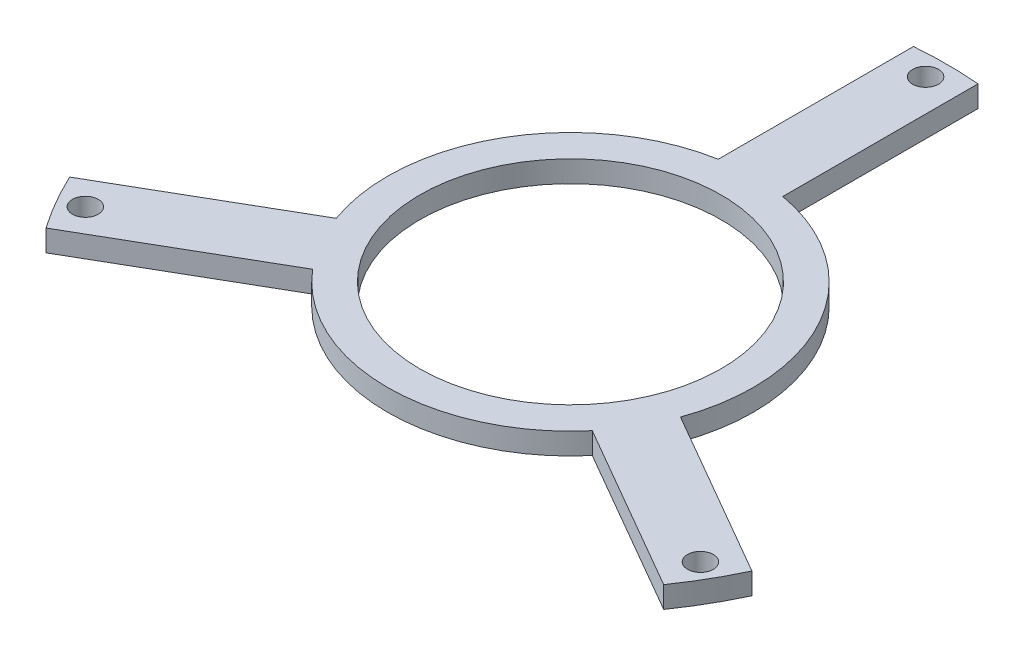
from build123d import *

# Parameters (mm, degrees)
SKETCH_1_R      = 70
SKETCH_1_R_2    = 6
EXTRUDE_1_DEPTH = 10


with BuildPart() as part:
    # 草图1 → 凸台-拉伸1 (new body)
    with BuildSketch(Plane(origin=(0, 0, 0), x_dir=(1, 0, 0), z_dir=(0, 1, 0))):
        with BuildLine():
            Line((143.496688705, -100.168359928), (64.956883731, -54.823382383))
            ThreePointArc((64.956883731, -54.823382383), (0, -85), (-64.956883731, -54.823382383))
            Line((-64.956883731, -54.823382383), (-143.496688705, -100.168359928))
            ThreePointArc((-143.496688705, -100.168359928), (-151.554445662, -87.5), (-158.496688705, -74.187597814))
            Line((-158.496688705, -74.187597814), (-79.956883731, -28.84262027))
            ThreePointArc((-79.956883731, -28.84262027), (-73.612159322, 42.5), (-15, 83.666002653))
            Line((-15, 83.666002653), (-15, 174.355957742))
            ThreePointArc((-15, 174.355957742), (0, 175), (15, 174.355957742))
            Line((15, 174.355957742), (15, 83.666002653))
            ThreePointArc((15, 83.666002653), (73.612159322, 42.5), (79.956883731, -28.84262027))
            Line((79.956883731, -28.84262027), (158.496688705, -74.187597814))
            ThreePointArc((158.496688705, -74.187597814), (151.554445662, -87.5), (143.496688705, -100.168359928))
        make_face()
        Circle(SKETCH_1_R, mode=Mode.SUBTRACT)
        with Locations((0, 165)):
            Circle(SKETCH_1_R_2, mode=Mode.SUBTRACT)
        with Locations((142.894191624, -82.5)):
            Circle(SKETCH_1_R_2, mode=Mode.SUBTRACT)
        with Locations((-142.894191624, -82.5)):
            Circle(SKETCH_1_R_2, mode=Mode.SUBTRACT)
    extrude(amount=EXTRUDE_1_DEPTH)


solid = part.part
